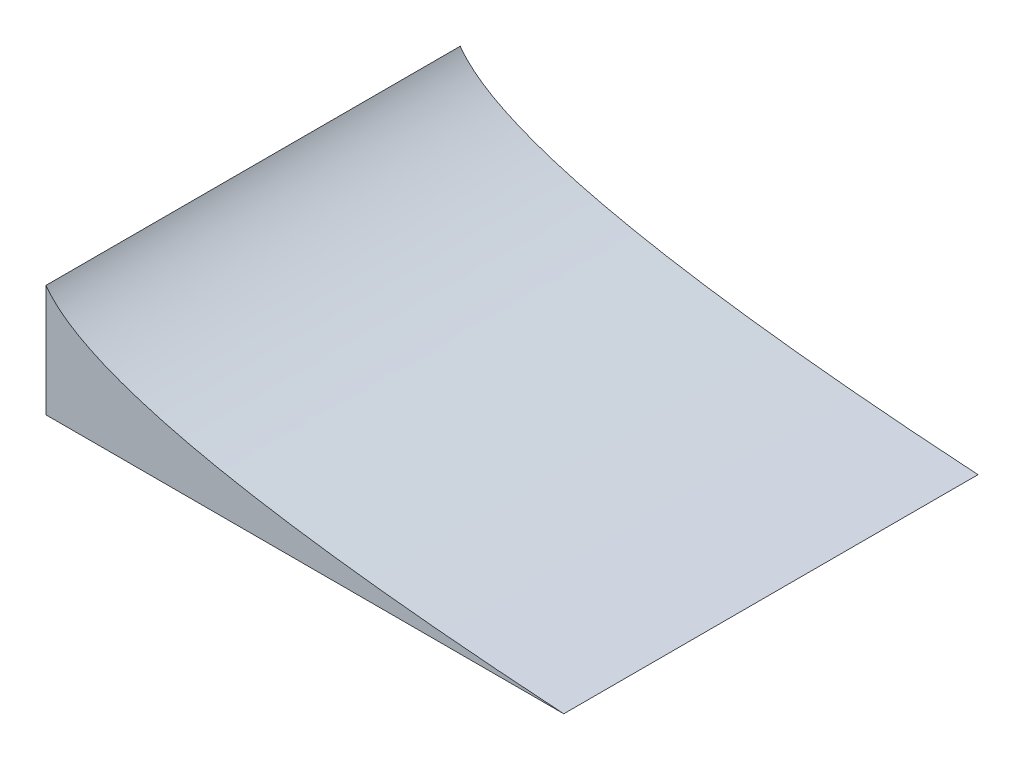
from build123d import *

# Parameters (mm, degrees)
BOSS_EXTRUDE1_DEPTH = 609.6


with BuildPart() as part:
    # Sketch1 → Boss-Extrude1 (new body)
    with BuildSketch(Plane.XY):
        with BuildLine():
            Line((-381, 0), (381, 0))
            add(Edge.make_bspline(
                [(-381, 165.1), (-296.003203858, 43.711995011), (381, 0)],
                knots=[0, 0, 0, 1, 1, 1], degree=2))
            Line((-381, 165.1), (-381, 0))
        make_face()
    extrude(amount=-BOSS_EXTRUDE1_DEPTH)


solid = part.part
